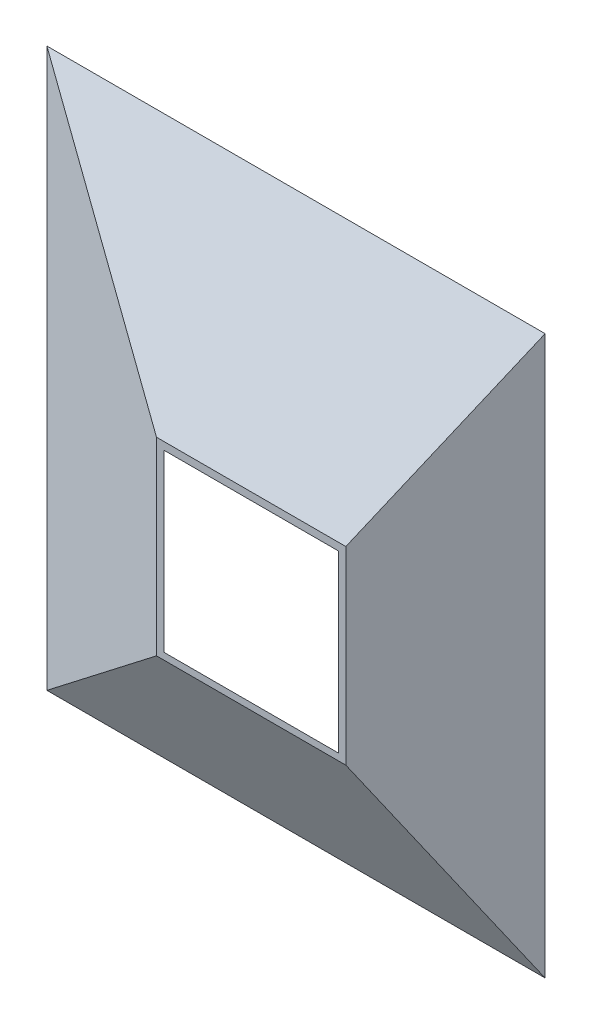
from build123d import *

# Parameters (mm, degrees)
SKETCH1_W               = 500
SKETCH1_H               = 560
BOSS_EXTRUDE1_DEPTH     = 100
CUT_EXTRUDE2_DEPTH      = 560
CUT_EXTRUDE4_DEPTH      = 560
CUT_EXTRUDE5_DEPTH      = 281
CUT_EXTRUDE5_DEPTH_BACK = 281
SKETCH9_W               = 476.487053383
SKETCH9_H               = 534.084389506
SKETCH8_W               = 174.861253259
SKETCH8_H               = 175.603763888


with BuildPart() as part:
    # Sketch1 → Boss-Extrude1 (new body)
    with BuildSketch(Plane.XY):
        Rectangle(SKETCH1_W, SKETCH1_H)
    extrude(amount=BOSS_EXTRUDE1_DEPTH)

    # Sketch2 → Cut-Extrude2 (cut)
    with BuildSketch(Plane(origin=(0, 280, 0), x_dir=(1, 0, 0), z_dir=(0, 1, 0))):
        Polygon((250, -100), (150, -100), (250, 0), align=None)
    extrude(amount=-CUT_EXTRUDE2_DEPTH, mode=Mode.SUBTRACT)

    # Sketch6 → Cut-Extrude4 (cut)
    with BuildSketch(Plane.ZY.offset(250)):
        Polygon((100, 95), (0, 280), (100, 280), align=None)
        Polygon((100, -95), (0, -280), (100, -280), align=None)
    extrude(amount=-CUT_EXTRUDE4_DEPTH, mode=Mode.SUBTRACT)

    # Sketch7 → Cut-Extrude5 (cut, two sides)
    with BuildSketch(Plane(origin=(0, 0, 0), x_dir=(1, 0, 0), z_dir=(0, 1, 0))) as cut_extrude5_sk:
        Polygon((-250, 0), (-250, -100), (-40, -100), align=None)
    extrude(amount=CUT_EXTRUDE5_DEPTH, mode=Mode.SUBTRACT)
    extrude(cut_extrude5_sk.sketch, amount=-CUT_EXTRUDE5_DEPTH_BACK, mode=Mode.SUBTRACT)

    # Sketch9 → Cut-Loft1 section 0
    with BuildSketch(Plane(origin=(0, 0, 0), x_dir=(-1, 0, 0), z_dir=(0, 0, -1))):
        with Locations((-2.945318325, 2.618060733)):
            Rectangle(SKETCH9_W, SKETCH9_H)
    # Sketch8 → Cut-Loft1 section 1
    with BuildSketch(Plane.XY.offset(100)):
        with Locations((55.010720812, -0.38064907)):
            Rectangle(SKETCH8_W, SKETCH8_H)
    loft(mode=Mode.SUBTRACT)


solid = part.part
